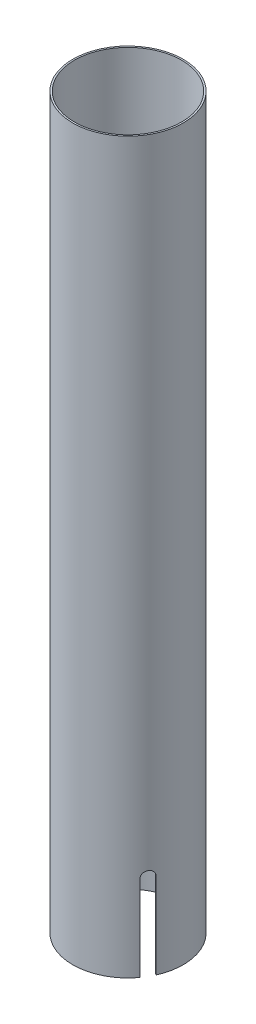
from build123d import *

# Parameters (mm, degrees)
SKETCH1_R           = 65.4431
SKETCH1_R_2         = 63.5
BOSS_EXTRUDE1_DEPTH = 863.6
CUT_EXTRUDE1_DEPTH  = 66.4431
CIRPATTERN1_COUNT   = 3


with BuildPart() as part:
    # Sketch1 → Boss-Extrude1 (new body)
    with BuildSketch(Plane(origin=(0, 0, 0), x_dir=(1, 0, 0), z_dir=(0, 1, 0))):
        Circle(SKETCH1_R)
        Circle(SKETCH1_R_2, mode=Mode.SUBTRACT)
    extrude(amount=BOSS_EXTRUDE1_DEPTH)

    # Sketch2 → Cut-Extrude1 (cut, through all)
    with BuildSketch(Plane.XY):
        with BuildLine():
            Line((7, 0), (7, 101.6))
            ThreePointArc((7, 101.6), (0, 108.6), (-7, 101.6))
            Line((-7, 101.6), (-7, 0))
            Line((-7, 0), (7, 0))
        make_face()
    cut_extrude1 = extrude(amount=-CUT_EXTRUDE1_DEPTH, mode=Mode.SUBTRACT)

    # CirPattern1: Cut-Extrude1 ×3 about axis
    cirpattern1_axis = Axis((0, 0, 0), (0, 1, 0))
    for i in range(1, CIRPATTERN1_COUNT):
        add(cut_extrude1.rotate(cirpattern1_axis, i * 360 / CIRPATTERN1_COUNT), mode=Mode.SUBTRACT)


solid = part.part
